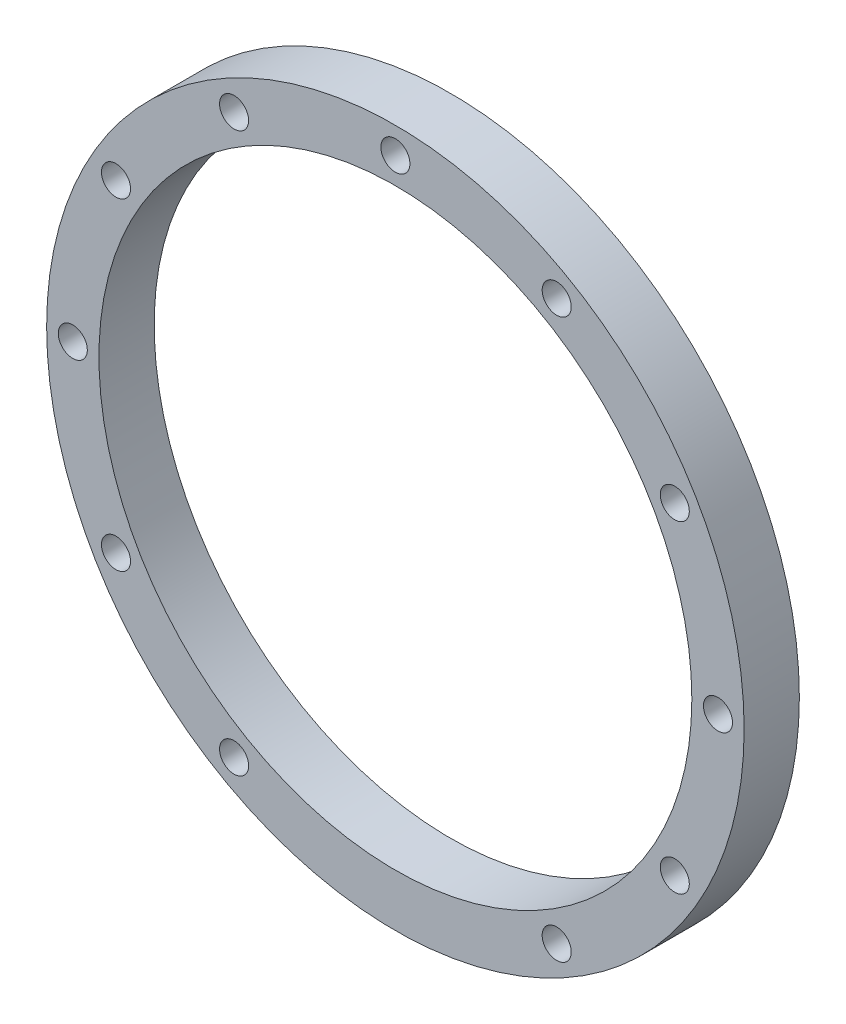
from build123d import *

# Parameters (mm, degrees)
ESBO_O1_R                = 60
RESSALTO_EXTRUS_O1_DEPTH = 9.5
ESBO_O2_R                = 51
ESBO_O2_R_2              = 2.5
CORTE_EXTRUS_O1_DEPTH    = 10.5


with BuildPart() as part:
    # Esboço1 → Ressalto-extrusão1 (new body)
    with BuildSketch(Plane.XY):
        Circle(ESBO_O1_R)
    extrude(amount=RESSALTO_EXTRUS_O1_DEPTH)

    # Esboço2 → Corte-extrusão1 (cut, through all)
    with BuildSketch(Plane.XY.offset(9.5)):
        Circle(ESBO_O2_R)
        with Locations((0, 55.5)):
            Circle(ESBO_O2_R_2)
        with Locations((27.75, 48.06440991)):
            Circle(ESBO_O2_R_2)
        with Locations((48.06440991, 27.75)):
            Circle(ESBO_O2_R_2)
        with Locations((55.5, 0)):
            Circle(ESBO_O2_R_2)
        with Locations((48.06440991, -27.75)):
            Circle(ESBO_O2_R_2)
        with Locations((27.75, -48.06440991)):
            Circle(ESBO_O2_R_2)
        with Locations((-27.75, -48.06440991)):
            Circle(ESBO_O2_R_2)
        with Locations((-48.06440991, -27.75)):
            Circle(ESBO_O2_R_2)
        with Locations((-55.5, 0)):
            Circle(ESBO_O2_R_2)
        with Locations((-48.06440991, 27.75)):
            Circle(ESBO_O2_R_2)
        with Locations((-27.75, 48.06440991)):
            Circle(ESBO_O2_R_2)
    extrude(amount=-CORTE_EXTRUS_O1_DEPTH, mode=Mode.SUBTRACT)


solid = part.part
